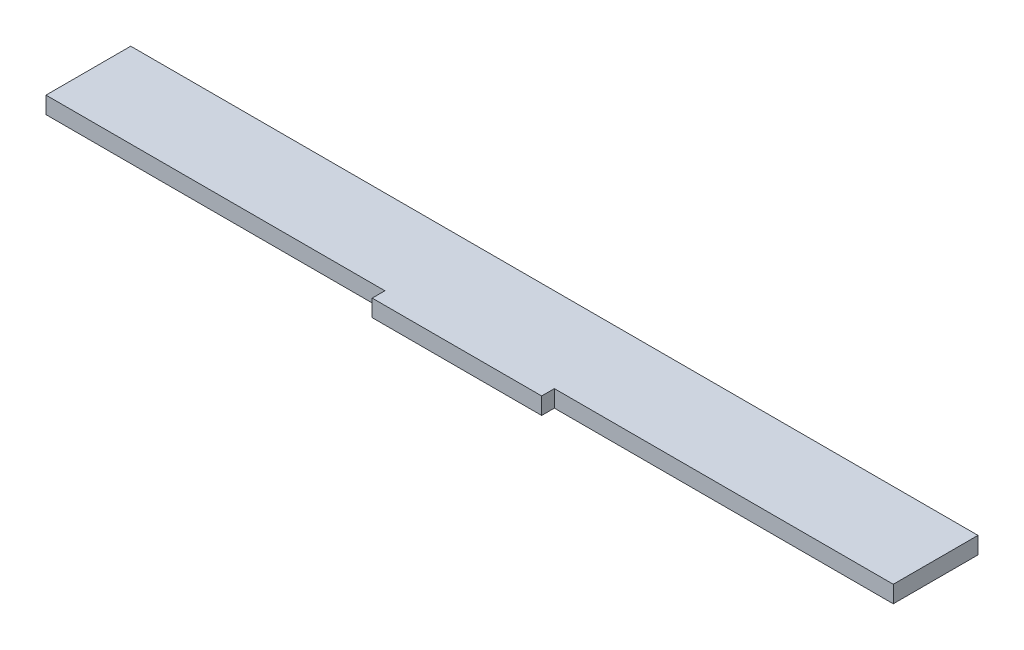
from build123d import *

# Parameters (mm, degrees)
SKETCH1_W      = 200
SKETCH1_H      = 20
SKETCH1_W_2    = 40
SKETCH1_H_2    = 3
EXTRUDE1_DEPTH = 4


with BuildPart() as part:
    # Sketch1 → Extrude1 (new body)
    with BuildSketch(Plane(origin=(0, 0, 0), x_dir=(1, 0, 0), z_dir=(0, 1, 0))):
        Rectangle(SKETCH1_W, SKETCH1_H)
        with Locations((0, -11.5)):
            Rectangle(SKETCH1_W_2, SKETCH1_H_2)
    extrude(amount=EXTRUDE1_DEPTH)


solid = part.part
